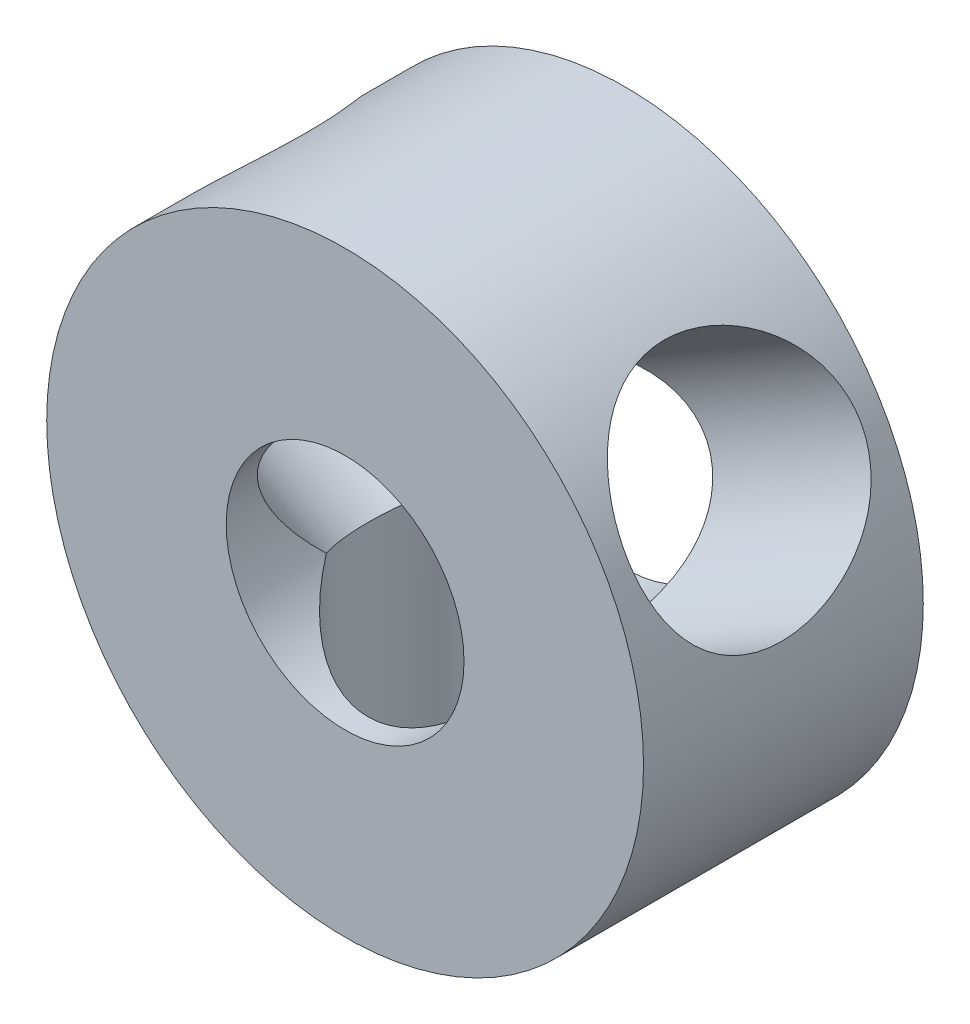
from build123d import *

# Parameters (mm, degrees)
SKETCH1_R           = 32
SKETCH1_R_2         = 12.75
BOSS_EXTRUDE1_DEPTH = 15
SKETCH2_R           = 12.55
CUT_EXTRUDE1_DEPTH  = 33
CIRPATTERN1_COUNT   = 3


with BuildPart() as part:
    # Sketch1 → Boss-Extrude1 (new body, symmetric)
    with BuildSketch(Plane.XY):
        Circle(SKETCH1_R)
        Circle(SKETCH1_R_2, mode=Mode.SUBTRACT)
    extrude(amount=BOSS_EXTRUDE1_DEPTH, both=True)

    # Sketch2 → Cut-Extrude1 (cut, through all)
    with BuildSketch(Plane(origin=(0, 0, 0), x_dir=(1, 0, 0), z_dir=(0, 1, 0))):
        Circle(SKETCH2_R)
    cut_extrude1 = extrude(amount=-CUT_EXTRUDE1_DEPTH, mode=Mode.SUBTRACT)

    # CirPattern1: Cut-Extrude1 ×3 about axis
    cirpattern1_axis = Axis((0, 0, 15), (0, 0, -1))
    for i in range(1, CIRPATTERN1_COUNT):
        add(cut_extrude1.rotate(cirpattern1_axis, i * 360 / CIRPATTERN1_COUNT), mode=Mode.SUBTRACT)


solid = part.part
